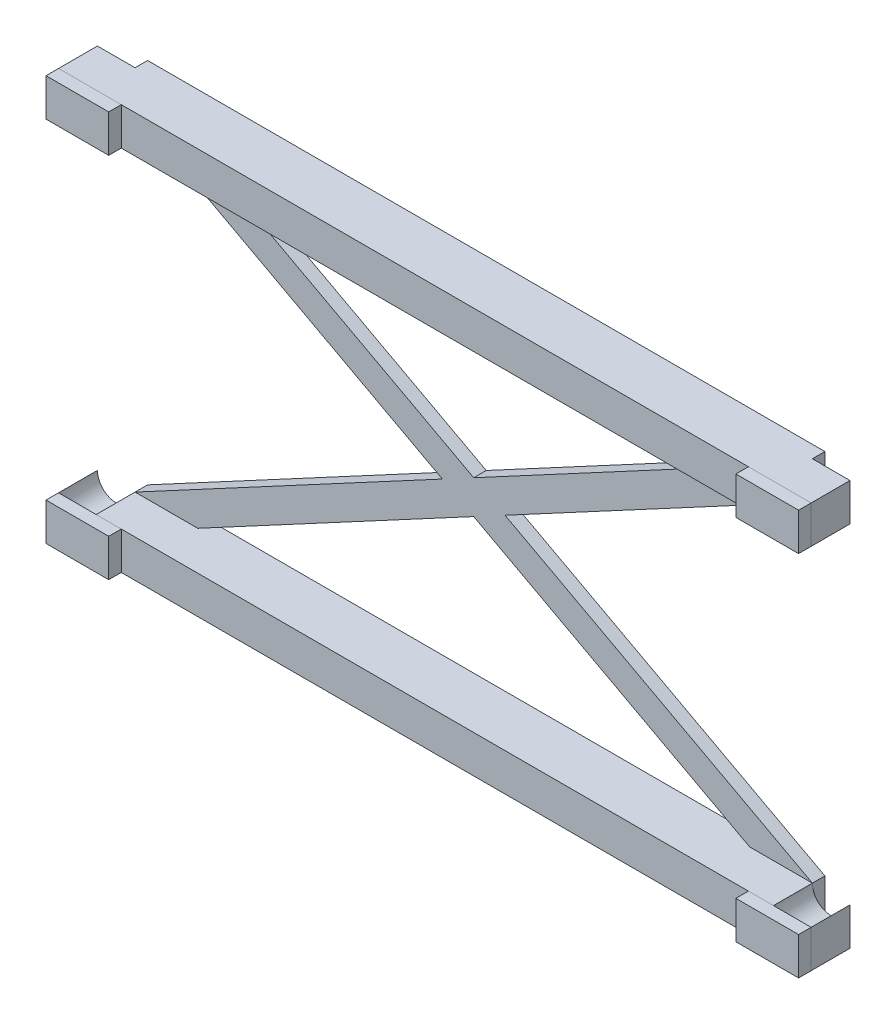
from build123d import *

# Parameters (mm, degrees)
BOSS_EXTRUDE1_DEPTH   = 3.1
BOSS_EXTRUDE1_2_DEPTH = 3.1
BOSS_EXTRUDE2_DEPTH   = 1
CUT_EXTRUDE1_DEPTH    = 2
SKETCH2_W             = 5
SKETCH2_H             = 3
BOSS_EXTRUDE3_DEPTH   = 1
BOSS_EXTRUDE3_2_DEPTH = 1
BOSS_EXTRUDE3_3_DEPTH = 1
BOSS_EXTRUDE3_4_DEPTH = 1


with BuildPart() as part:
    # female_slide → Boss-Extrude1 (new body)
    with BuildSketch(Plane.XY):
        with BuildLine():
            Line((-27, 3.15), (27, 3.15))
            ThreePointArc((27, 3.15), (28.5, 4.65), (30, 3.15))
            Line((30, 3.15), (30, 6.15))
            Line((30, 6.15), (-30, 6.15))
            Line((-30, 6.15), (-30, 3.15))
            ThreePointArc((-30, 3.15), (-28.5, 4.65), (-27, 3.15))
        make_face()
    extrude(amount=BOSS_EXTRUDE1_DEPTH)



with BuildPart() as body_2:
    # female_slide → Boss-Extrude1 2 (new body)
    with BuildSketch(Plane.XY):
        with BuildLine():
            Line((-27, -23.15), (27, -23.15))
            ThreePointArc((27, -23.15), (28.5, -24.65), (30, -23.15))
            Line((30, -23.15), (30, -26.15))
            Line((30, -26.15), (-30, -26.15))
            Line((-30, -26.15), (-30, -23.15))
            ThreePointArc((-30, -23.15), (-28.5, -24.65), (-27, -23.15))
        make_face()
    extrude(amount=BOSS_EXTRUDE1_2_DEPTH)


with BuildPart() as part_1:
    add(part.part)

    add(body_2.part)  # Boss-Extrude2 merges body 2
    # X_back → Boss-Extrude2 (add)
    with BuildSketch(Plane.XY):
        Polygon((22, 6.15), (-22, 6.15), (-27, 6.15), (-27, 3.15), (-2.5, -10), (-27, -23.15), (-27, -26.15), (-22, -26.15), (22, -26.15), (27, -26.15), (27, -23.15), (2.5, -10), (27, 3.15), (27, 6.15), align=None)
    extrude(amount=-BOSS_EXTRUDE2_DEPTH)

    # Sketch1 → Cut-Extrude1 (cut, through all)
    with BuildSketch(Plane.XY):
        Polygon((22, 3.15), (-22, 3.15), (0, -8.658163265), align=None)
        Polygon((0, -11.341836735), (-22, -23.15), (22, -23.15), align=None)
    extrude(amount=-CUT_EXTRUDE1_DEPTH, mode=Mode.SUBTRACT)


with BuildPart() as body_2_2:
    # Sketch2 → Boss-Extrude3 (new body)
    with BuildSketch(Plane.XY.offset(3.1)):
        with Locations((27.5, 4.65)):
            Rectangle(SKETCH2_W, SKETCH2_H)
    extrude(amount=BOSS_EXTRUDE3_DEPTH)


with BuildPart() as body_3:
    # Sketch2 → Boss-Extrude3 2 (new body)
    with BuildSketch(Plane.XY.offset(3.1)):
        with Locations((-27.5, 4.65)):
            Rectangle(SKETCH2_W, SKETCH2_H)
    extrude(amount=BOSS_EXTRUDE3_2_DEPTH)


with BuildPart() as body_4:
    # Sketch2 → Boss-Extrude3 3 (new body)
    with BuildSketch(Plane.XY.offset(3.1)):
        with Locations((27.5, -24.65)):
            Rectangle(SKETCH2_W, SKETCH2_H)
    extrude(amount=BOSS_EXTRUDE3_3_DEPTH)


with BuildPart() as body_5:
    # Sketch2 → Boss-Extrude3 4 (new body)
    with BuildSketch(Plane.XY.offset(3.1)):
        with Locations((-27.5, -24.65)):
            Rectangle(SKETCH2_W, SKETCH2_H)
    extrude(amount=BOSS_EXTRUDE3_4_DEPTH)


solid = Compound([part_1.part, body_2_2.part, body_3.part, body_4.part, body_5.part])
